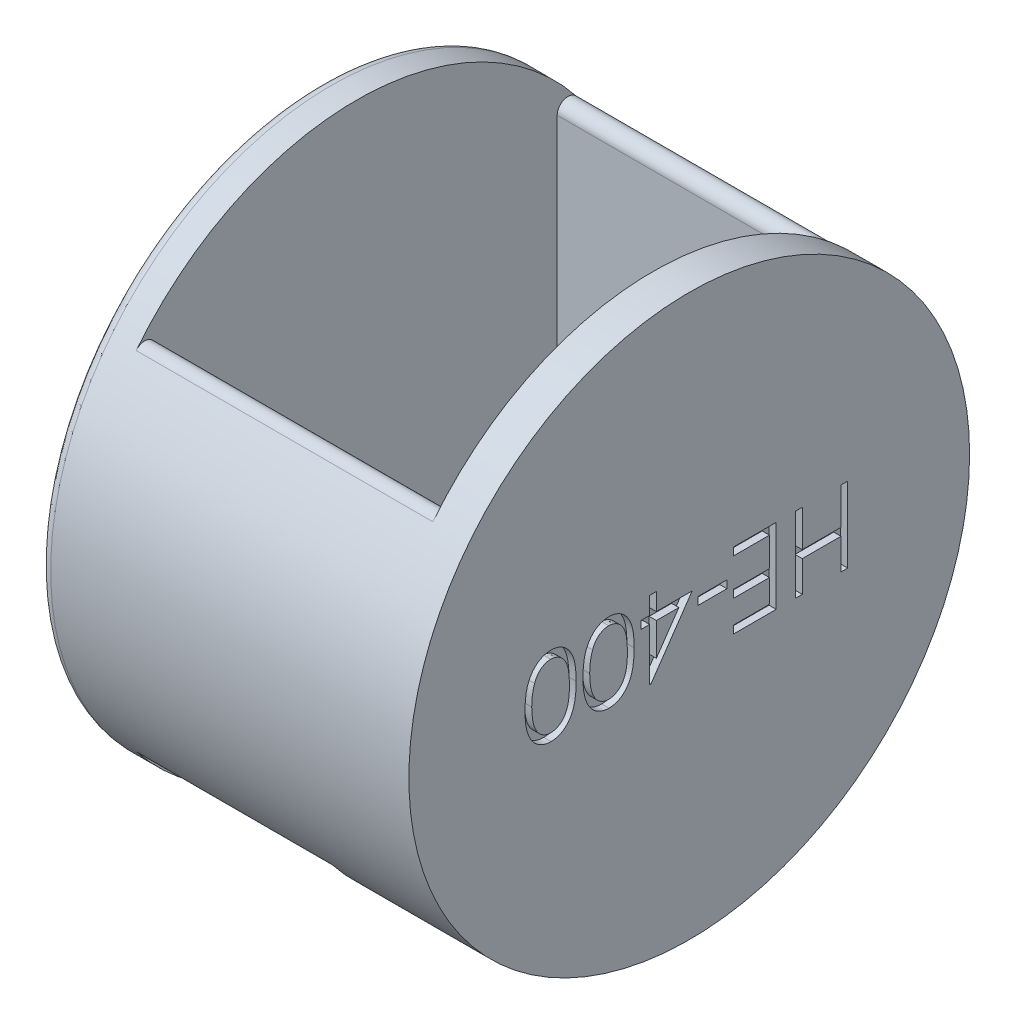
from build123d import *

# Parameters (mm, degrees)
SKETCH1_R                = 14.097
BOSS_EXTRUDE1_DEPTH      = 2.54
SKETCH1_4_R              = 19.685
SKETCH1_4_R_2            = 14.097
BOSS_EXTRUDE2_DEPTH      = 23.368
SKETCH2_R                = 19.685
BOSS_EXTRUDE3_DEPTH      = 2.54
CUT_EXTRUDE14_DEPTH      = 52.075635963
CUT_EXTRUDE14_DEPTH_BACK = 52.075635963
SKETCH5_W                = 13.716
SKETCH5_H                = 28.194
SKETCH5_7_W              = 7.112
SKETCH5_7_H              = 28.194
CUT_EXTRUDE15_DEPTH      = 19.685
SKETCH6_W                = 2.03525641
SKETCH6_H                = 0.542735043
CUT_EXTRUDE16_DEPTH      = 0.508
FILLET1_R                = 0.762


with BuildPart() as part:
    # Sketch1 → Boss-Extrude1 (new body)
    with BuildSketch(Plane(origin=(0, 0, 0), x_dir=(0, 0, -1), z_dir=(1, 0, 0))):
        Circle(SKETCH1_R)
    extrude(amount=BOSS_EXTRUDE1_DEPTH)

    # Sketch1_4 → Boss-Extrude2 (add)
    with BuildSketch(Plane(origin=(0, 0, 0), x_dir=(0, 0, -1), z_dir=(1, 0, 0))):
        Circle(SKETCH1_4_R)
        Circle(SKETCH1_4_R_2, mode=Mode.SUBTRACT)
    extrude(amount=BOSS_EXTRUDE2_DEPTH)

    # Sketch2 → Boss-Extrude3 (add)
    with BuildSketch(Plane(origin=(23.368, 0, 0), x_dir=(0, 0, -1), z_dir=(1, 0, 0))):
        Circle(SKETCH2_R)
    extrude(amount=BOSS_EXTRUDE3_DEPTH)

    # Sketch5 → Cut-Extrude14 (cut, two sides: drawn at the far end of the back side and taken through both)
    with BuildSketch(Plane(origin=(0, 19.685, 0), x_dir=(1, 0, 0), z_dir=(0, 1, 0)).offset(-CUT_EXTRUDE14_DEPTH_BACK)):
        with Locations((9.398, 0)):
            Rectangle(SKETCH5_W, SKETCH5_H)
    extrude(amount=CUT_EXTRUDE14_DEPTH + CUT_EXTRUDE14_DEPTH_BACK, mode=Mode.SUBTRACT)

    # Sketch5_7 → Cut-Extrude15 (cut)
    with BuildSketch(Plane(origin=(0, 19.685, 0), x_dir=(1, 0, 0), z_dir=(0, 1, 0))):
        with Locations((19.812, 0)):
            Rectangle(SKETCH5_7_W, SKETCH5_7_H)
    extrude(amount=-CUT_EXTRUDE15_DEPTH, mode=Mode.SUBTRACT)

    # Sketch6 → Cut-Extrude16 (cut)
    # profile 1 of 6: a face of its own
    with BuildSketch(Plane(origin=(25.908, 0, 0), x_dir=(0, 0, -1), z_dir=(1, 0, 0))):
        with BuildLine():
            add(Edge.make_bspline(
                [(-7.9375, 0.002120016), (-7.937995932, -0.082693891), (-7.938959288, -0.247446129), (-7.949676305, -0.487513385), (-7.9674795, -0.712727157), (-7.991877676, -0.923098217), (-8.021568415, -1.1186809), (-8.061203789, -1.298952445), (-8.106277723, -1.464747501), (-8.158518351, -1.616605725), (-8.217462038, -1.756576419), (-8.281626134, -1.887235952), (-8.353512856, -2.008428241), (-8.429168701, -2.121938907), (-8.511241484, -2.226625612), (-8.599445794, -2.322017877), (-8.693004723, -2.409593944), (-8.792360964, -2.48791374), (-8.896567528, -2.556158994), (-9.00254185, -2.618021773), (-9.113306534, -2.666956938), (-9.226129508, -2.708802141), (-9.341919763, -2.741949196), (-9.460727739, -2.765005575), (-9.58266005, -2.779430136), (-9.664953796, -2.780814869), (-9.706689036, -2.781517136)],
                knots=[0, 0, 0, 0, 1.64625301, 3.197870201, 4.6634513, 6.030635694, 7.308242971, 8.501545196, 9.611429483, 10.641742253, 11.616230371, 12.55791849, 13.464870342, 14.34944951, 15.20427819, 16.044004467, 16.869007726, 17.689551165, 18.496129964, 19.285613293, 20.0683943, 20.843080271, 21.620342827, 22.403213977, 23.190190624, 24, 24, 24, 24], degree=3))
            add(Edge.make_bspline(
                [(-9.706689036, -2.781517136), (-9.748794038, -2.780933163), (-9.832568173, -2.779771262), (-9.955977623, -2.763416809), (-10.077237491, -2.742307643), (-10.194508026, -2.708452016), (-10.310006587, -2.667939368), (-10.420860957, -2.614483573), (-10.530984882, -2.556346245), (-10.635375579, -2.485423594), (-10.737152051, -2.407042394), (-10.832556867, -2.318059694), (-10.92402883, -2.2209381), (-11.008113079, -2.113511516), (-11.088413348, -1.997427109), (-11.161881358, -1.87171176), (-11.23004511, -1.736644069), (-11.2941859, -1.592850191), (-11.350275328, -1.436489169), (-11.400143312, -1.268536268), (-11.441018564, -1.087470592), (-11.474821678, -0.894300793), (-11.501059329, -0.68806991), (-11.520154648, -0.469195791), (-11.530244865, -0.237541505), (-11.532144715, -0.079157565), (-11.533119658, 0.002120016)],
                knots=[0, 0, 0, 0, 0.810910589, 1.61342667, 2.396193133, 3.181089899, 3.963115317, 4.752255436, 5.550715454, 6.36105385, 7.181178335, 8.024612154, 8.872680183, 9.750181803, 10.651284446, 11.591556747, 12.554036451, 13.566402641, 14.62422919, 15.753422176, 16.94128843, 18.199818041, 19.531985927, 20.947085226, 22.433341622, 24, 24, 24, 24], degree=3))
            add(Edge.make_bspline(
                [(-11.533119658, 0.002120016), (-11.532122052, 0.083042058), (-11.530173906, 0.241068301), (-11.520384288, 0.471695291), (-11.500547447, 0.689375069), (-11.476369925, 0.894423013), (-11.441510668, 1.086571091), (-11.402701899, 1.266851209), (-11.353199136, 1.43356942), (-11.298440137, 1.588590152), (-11.235191822, 1.731774906), (-11.167541426, 1.866285081), (-11.092976705, 1.991286968), (-11.014217251, 2.108107177), (-10.92854112, 2.214612444), (-10.838307045, 2.312820461), (-10.741976654, 2.401957757), (-10.639676263, 2.481264427), (-10.534298886, 2.552721332), (-10.424153492, 2.612931661), (-10.311818484, 2.665422781), (-10.196125432, 2.707619502), (-10.077812077, 2.740976177), (-9.956452353, 2.763683561), (-9.832551669, 2.779689407), (-9.748788517, 2.780905727), (-9.706689036, 2.781517052)],
                knots=[0, 0, 0, 0, 1.561431216, 3.049195289, 4.452146966, 5.778046447, 7.031138842, 8.218704273, 9.334037798, 10.384210803, 11.388620812, 12.352076869, 13.287433199, 14.19507451, 15.06813243, 15.922055533, 16.766344942, 17.596869952, 18.417486629, 19.220035357, 20.016159057, 20.807716045, 21.59340902, 22.384936649, 23.188266813, 24, 24, 24, 24], degree=3))
            add(Edge.make_bspline(
                [(-9.706689036, 2.781517052), (-9.664955251, 2.780808561), (-9.582664372, 2.779411555), (-9.460711052, 2.765076893), (-9.342075341, 2.741701887), (-9.226520072, 2.70995875), (-9.113808787, 2.669615088), (-9.005045495, 2.618299506), (-8.898794221, 2.558781187), (-8.795538229, 2.491068822), (-8.697251465, 2.413468923), (-8.603348026, 2.327658184), (-8.51628577, 2.231425166), (-8.434778993, 2.126305823), (-8.358495409, 2.012509414), (-8.286913108, 1.890389332), (-8.222944414, 1.758456952), (-8.162664248, 1.617726417), (-8.109526822, 1.464752379), (-8.063128202, 1.298389167), (-8.024009944, 1.11750203), (-7.992851705, 0.922082309), (-7.967326159, 0.712432527), (-7.949693856, 0.488218596), (-7.938964646, 0.249920762), (-7.937997124, 0.086227578), (-7.9375, 0.002120016)],
                knots=[0, 0, 0, 0, 0.810976328, 1.599087026, 2.383086309, 3.159618043, 3.926613167, 4.707144544, 5.494386734, 6.292609454, 7.104690378, 7.92621526, 8.762510248, 9.62398222, 10.509836085, 11.424023232, 12.373226806, 13.358118208, 14.398657954, 15.5185989, 16.713620699, 17.994156382, 19.364120462, 20.818119981, 22.365111093, 24, 24, 24, 24], degree=3))
        make_face()
        with BuildLine():
            add(Edge.make_bspline(
                [(-8.412393162, -4.2e-08), (-8.412577715, 0.070679255), (-8.412935895, 0.207853894), (-8.422022303, 0.406839949), (-8.434669655, 0.592746077), (-8.450580757, 0.765499715), (-8.474409875, 0.924497116), (-8.501445528, 1.070399217), (-8.533872934, 1.202936193), (-8.572430256, 1.323265481), (-8.616348478, 1.433093612), (-8.664223235, 1.535338827), (-8.716081944, 1.631244786), (-8.773114398, 1.720465462), (-8.836137709, 1.802502535), (-8.903745174, 1.877745626), (-8.976329911, 1.945888366), (-9.076787042, 2.026759991), (-9.208764022, 2.111314187), (-9.375899671, 2.184038831), (-9.547714784, 2.230037038), (-9.664365492, 2.235870398), (-9.722589476, 2.238782009)],
                knots=[0, 0, 0, 0, 1.459193451, 2.832007961, 4.111736495, 5.306635028, 6.412683014, 7.430020708, 8.369596877, 9.227877302, 10.036669781, 10.810175692, 11.557788084, 12.286326232, 12.994037279, 13.69140682, 14.37267704, 15.047194847, 16.352618509, 17.594157723, 18.799169539, 20, 20, 20, 20], degree=3))
            add(Edge.make_bspline(
                [(-9.722589476, 2.238782009), (-9.781147793, 2.236228925), (-9.898056707, 2.231131813), (-10.069754872, 2.186646233), (-10.235061227, 2.114326806), (-10.365519249, 2.031703575), (-10.464493977, 1.952515004), (-10.535433901, 1.885076976), (-10.600537976, 1.809544273), (-10.662287759, 1.728054835), (-10.718922187, 1.639044922), (-10.770422444, 1.542944454), (-10.817417495, 1.439486028), (-10.844191887, 1.367262736), (-10.857880943, 1.33033683)],
                knots=[0, 0, 0, 0, 1.353621445, 2.702441307, 4.075953605, 5.516772412, 6.261413105, 7.007624062, 7.778524365, 8.566925914, 9.372323995, 10.217594641, 11.088702136, 12, 12, 12, 12], degree=3))
            add(Edge.make_bspline(
                [(-10.857880943, 1.33033683), (-10.873834211, 1.283120438), (-10.906226186, 1.187250914), (-10.947972559, 1.03853444), (-10.980849532, 0.882501689), (-11.010427478, 0.720085144), (-11.030616027, 0.550087025), (-11.046865697, 0.373033325), (-11.056437093, 0.188790551), (-11.057623561, 0.06361241), (-11.058226496, -4.2e-08)],
                knots=[0, 0, 0, 0, 0.884706709, 1.796334032, 2.740027952, 3.714592787, 4.726048262, 5.777819803, 6.87074269, 8, 8, 8, 8], degree=3))
            add(Edge.make_bspline(
                [(-11.058226496, -4.2e-08), (-11.057561524, -0.063611127), (-11.056260535, -0.1880634), (-11.047712924, -0.370137188), (-11.033977623, -0.543370241), (-11.015387194, -0.707919709), (-10.989866471, -0.863492719), (-10.959218606, -1.010311872), (-10.923287556, -1.148337659), (-10.88207338, -1.27792579), (-10.835626237, -1.398611346), (-10.784313786, -1.510654121), (-10.729564349, -1.614658415), (-10.670059375, -1.710289705), (-10.606640761, -1.798106005), (-10.537031365, -1.876085838), (-10.465652722, -1.948022706), (-10.364137186, -2.028669234), (-10.232316193, -2.111546858), (-10.067154872, -2.185741148), (-9.896220027, -2.229651331), (-9.780424595, -2.235740701), (-9.722589476, -2.238782094)],
                knots=[0, 0, 0, 0, 1.313528337, 2.569860077, 3.762944266, 4.901481389, 5.988248151, 7.017139294, 7.997571128, 8.932104357, 9.823695246, 10.66607014, 11.475539426, 12.248954257, 12.990316782, 13.708962568, 14.405488541, 15.08007697, 16.381737273, 17.610043218, 18.806313575, 20, 20, 20, 20], degree=3))
            add(Edge.make_bspline(
                [(-9.722589476, -2.238782094), (-9.664051396, -2.235737102), (-9.546868594, -2.229641571), (-9.374145575, -2.18589607), (-9.207995524, -2.112074551), (-9.076452321, -2.02856675), (-8.976365918, -1.948335902), (-8.905142646, -1.879860571), (-8.837926465, -1.80532116), (-8.77520507, -1.723656045), (-8.718520589, -1.634605498), (-8.666031584, -1.5393948), (-8.618538786, -1.437301467), (-8.57445479, -1.327534037), (-8.536306583, -1.207007026), (-8.502006897, -1.074496482), (-8.475532701, -0.927645516), (-8.452025942, -0.767901464), (-8.434257504, -0.594942434), (-8.422110448, -0.408596221), (-8.412908297, -0.208916514), (-8.412568313, -0.071033637), (-8.412393162, -4.2e-08)],
                knots=[0, 0, 0, 0, 1.207779899, 2.417760083, 3.652287919, 4.947299644, 5.621638849, 6.297435916, 6.984320042, 7.691843698, 8.42018894, 9.161205785, 9.934506883, 10.743085206, 11.601138371, 12.542248028, 13.566483018, 14.679455109, 15.87477181, 17.154161492, 18.533899613, 20, 20, 20, 20], degree=3))
        make_face(mode=Mode.SUBTRACT)
    # profile 2 of 6: a face of its own
    with BuildSketch(Plane(origin=(25.908, 0, 0), x_dir=(0, 0, -1), z_dir=(1, 0, 0))):
        with BuildLine():
            add(Edge.make_bspline(
                [(-3.866987179, 0.002120016), (-3.867483112, -0.082693891), (-3.868446467, -0.247446129), (-3.879163485, -0.487513385), (-3.89696668, -0.712727157), (-3.921364855, -0.923098217), (-3.951055595, -1.1186809), (-3.990690969, -1.298952445), (-4.035764902, -1.464747501), (-4.08800553, -1.616605725), (-4.146949218, -1.756576419), (-4.211113313, -1.887235952), (-4.283000035, -2.008428241), (-4.358655881, -2.121938907), (-4.440728663, -2.226625612), (-4.528932974, -2.322017877), (-4.622491902, -2.409593944), (-4.721848143, -2.48791374), (-4.826054708, -2.556158994), (-4.932029029, -2.618021773), (-5.042793713, -2.666956938), (-5.155616688, -2.708802141), (-5.271406943, -2.741949196), (-5.390214919, -2.765005575), (-5.512147229, -2.779430136), (-5.594440976, -2.780814869), (-5.636176215, -2.781517136)],
                knots=[0, 0, 0, 0, 1.64625301, 3.197870201, 4.6634513, 6.030635694, 7.308242971, 8.501545196, 9.611429483, 10.641742253, 11.616230371, 12.55791849, 13.464870342, 14.34944951, 15.20427819, 16.044004467, 16.869007726, 17.689551165, 18.496129964, 19.285613293, 20.0683943, 20.843080271, 21.620342827, 22.403213977, 23.190190624, 24, 24, 24, 24], degree=3))
            add(Edge.make_bspline(
                [(-5.636176215, -2.781517136), (-5.678281217, -2.780933163), (-5.762055352, -2.779771262), (-5.885464803, -2.763416809), (-6.006724671, -2.742307643), (-6.123995205, -2.708452016), (-6.239493766, -2.667939368), (-6.350348136, -2.614483573), (-6.460472061, -2.556346245), (-6.564862758, -2.485423594), (-6.66663923, -2.407042394), (-6.762044047, -2.318059694), (-6.85351601, -2.2209381), (-6.937600259, -2.113511516), (-7.017900528, -1.997427109), (-7.091368538, -1.87171176), (-7.159532289, -1.736644069), (-7.22367308, -1.592850191), (-7.279762507, -1.436489169), (-7.329630492, -1.268536268), (-7.370505743, -1.087470592), (-7.404308857, -0.894300793), (-7.430546509, -0.68806991), (-7.449641828, -0.469195791), (-7.459732044, -0.237541505), (-7.461631895, -0.079157565), (-7.462606838, 0.002120016)],
                knots=[0, 0, 0, 0, 0.810910589, 1.61342667, 2.396193133, 3.181089899, 3.963115317, 4.752255436, 5.550715454, 6.36105385, 7.181178335, 8.024612154, 8.872680183, 9.750181803, 10.651284446, 11.591556747, 12.554036451, 13.566402641, 14.62422919, 15.753422176, 16.94128843, 18.199818041, 19.531985927, 20.947085226, 22.433341622, 24, 24, 24, 24], degree=3))
            add(Edge.make_bspline(
                [(-7.462606838, 0.002120016), (-7.461609232, 0.083042058), (-7.459661086, 0.241068301), (-7.449871467, 0.471695291), (-7.430034626, 0.689375069), (-7.405857104, 0.894423013), (-7.370997848, 1.086571091), (-7.332189079, 1.266851209), (-7.282686316, 1.43356942), (-7.227927317, 1.588590152), (-7.164679002, 1.731774906), (-7.097028605, 1.866285081), (-7.022463885, 1.991286968), (-6.943704431, 2.108107177), (-6.858028299, 2.214612444), (-6.767794224, 2.312820461), (-6.671463833, 2.401957757), (-6.569163442, 2.481264427), (-6.463786065, 2.552721332), (-6.353640672, 2.612931661), (-6.241305663, 2.665422781), (-6.125612612, 2.707619502), (-6.007299257, 2.740976177), (-5.885939533, 2.763683561), (-5.762038848, 2.779689407), (-5.678275697, 2.780905727), (-5.636176215, 2.781517052)],
                knots=[0, 0, 0, 0, 1.561431216, 3.049195289, 4.452146966, 5.778046447, 7.031138842, 8.218704273, 9.334037798, 10.384210803, 11.388620812, 12.352076869, 13.287433199, 14.19507451, 15.06813243, 15.922055533, 16.766344942, 17.596869952, 18.417486629, 19.220035357, 20.016159057, 20.807716045, 21.59340902, 22.384936649, 23.188266813, 24, 24, 24, 24], degree=3))
            add(Edge.make_bspline(
                [(-5.636176215, 2.781517052), (-5.59444243, 2.780808561), (-5.512151552, 2.779411555), (-5.390198231, 2.765076893), (-5.271562521, 2.741701887), (-5.156007252, 2.70995875), (-5.043295966, 2.669615088), (-4.934532675, 2.618299506), (-4.828281401, 2.558781187), (-4.725025408, 2.491068822), (-4.626738644, 2.413468923), (-4.532835206, 2.327658184), (-4.44577295, 2.231425166), (-4.364266172, 2.126305823), (-4.287982589, 2.012509414), (-4.216400287, 1.890389332), (-4.152431593, 1.758456952), (-4.092151428, 1.617726417), (-4.039014001, 1.464752379), (-3.992615381, 1.298389167), (-3.953497123, 1.11750203), (-3.922338885, 0.922082309), (-3.896813339, 0.712432527), (-3.879181036, 0.488218596), (-3.868451826, 0.249920762), (-3.867484304, 0.086227578), (-3.866987179, 0.002120016)],
                knots=[0, 0, 0, 0, 0.810976328, 1.599087026, 2.383086309, 3.159618043, 3.926613167, 4.707144544, 5.494386734, 6.292609454, 7.104690378, 7.92621526, 8.762510248, 9.62398222, 10.509836085, 11.424023232, 12.373226806, 13.358118208, 14.398657954, 15.5185989, 16.713620699, 17.994156382, 19.364120462, 20.818119981, 22.365111093, 24, 24, 24, 24], degree=3))
        make_face()
        with BuildLine():
            add(Edge.make_bspline(
                [(-4.341880342, -4.2e-08), (-4.342064894, 0.070679255), (-4.342423075, 0.207853894), (-4.351509483, 0.406839949), (-4.364156835, 0.592746077), (-4.380067937, 0.765499715), (-4.403897054, 0.924497116), (-4.430932708, 1.070399217), (-4.463360114, 1.202936193), (-4.501917435, 1.323265481), (-4.545835658, 1.433093612), (-4.593710415, 1.535338827), (-4.645569124, 1.631244786), (-4.702601578, 1.720465462), (-4.765624889, 1.802502535), (-4.833232354, 1.877745626), (-4.90581709, 1.945888366), (-5.006274221, 2.026759991), (-5.138251201, 2.111314187), (-5.30538685, 2.184038831), (-5.477201963, 2.230037038), (-5.593852671, 2.235870398), (-5.652076656, 2.238782009)],
                knots=[0, 0, 0, 0, 1.459193451, 2.832007961, 4.111736495, 5.306635028, 6.412683014, 7.430020708, 8.369596877, 9.227877302, 10.036669781, 10.810175692, 11.557788084, 12.286326232, 12.994037279, 13.69140682, 14.37267704, 15.047194847, 16.352618509, 17.594157723, 18.799169539, 20, 20, 20, 20], degree=3))
            add(Edge.make_bspline(
                [(-5.652076656, 2.238782009), (-5.710634972, 2.236228925), (-5.827543887, 2.231131813), (-5.999242052, 2.186646233), (-6.164548406, 2.114326806), (-6.295006429, 2.031703575), (-6.393981156, 1.952515004), (-6.46492108, 1.885076976), (-6.530025155, 1.809544273), (-6.591774939, 1.728054835), (-6.648409367, 1.639044922), (-6.699909623, 1.542944454), (-6.746904674, 1.439486028), (-6.773679066, 1.367262736), (-6.787368122, 1.33033683)],
                knots=[0, 0, 0, 0, 1.353621445, 2.702441307, 4.075953605, 5.516772412, 6.261413105, 7.007624062, 7.778524365, 8.566925914, 9.372323995, 10.217594641, 11.088702136, 12, 12, 12, 12], degree=3))
            add(Edge.make_bspline(
                [(-6.787368122, 1.33033683), (-6.80332139, 1.283120438), (-6.835713366, 1.187250914), (-6.877459739, 1.03853444), (-6.910336712, 0.882501689), (-6.939914657, 0.720085144), (-6.960103206, 0.550087025), (-6.976352876, 0.373033325), (-6.985924272, 0.188790551), (-6.987110741, 0.06361241), (-6.987713675, -4.2e-08)],
                knots=[0, 0, 0, 0, 0.884706709, 1.796334032, 2.740027952, 3.714592787, 4.726048262, 5.777819803, 6.87074269, 8, 8, 8, 8], degree=3))
            add(Edge.make_bspline(
                [(-6.987713675, -4.2e-08), (-6.987048703, -0.063611127), (-6.985747715, -0.1880634), (-6.977200104, -0.370137188), (-6.963464803, -0.543370241), (-6.944874374, -0.707919709), (-6.91935365, -0.863492719), (-6.888705785, -1.010311872), (-6.852774736, -1.148337659), (-6.811560559, -1.27792579), (-6.765113416, -1.398611346), (-6.713800965, -1.510654121), (-6.659051528, -1.614658415), (-6.599546555, -1.710289705), (-6.53612794, -1.798106005), (-6.466518544, -1.876085838), (-6.395139901, -1.948022706), (-6.293624366, -2.028669234), (-6.161803373, -2.111546858), (-5.996642052, -2.185741148), (-5.825707207, -2.229651331), (-5.709911775, -2.235740701), (-5.652076656, -2.238782094)],
                knots=[0, 0, 0, 0, 1.313528337, 2.569860077, 3.762944266, 4.901481389, 5.988248151, 7.017139294, 7.997571128, 8.932104357, 9.823695246, 10.66607014, 11.475539426, 12.248954257, 12.990316782, 13.708962568, 14.405488541, 15.08007697, 16.381737273, 17.610043218, 18.806313575, 20, 20, 20, 20], degree=3))
            add(Edge.make_bspline(
                [(-5.652076656, -2.238782094), (-5.593538576, -2.235737102), (-5.476355773, -2.229641571), (-5.303632755, -2.18589607), (-5.137482704, -2.112074551), (-5.0059395, -2.02856675), (-4.905853098, -1.948335902), (-4.834629826, -1.879860571), (-4.767413645, -1.80532116), (-4.70469225, -1.723656045), (-4.648007768, -1.634605498), (-4.595518763, -1.5393948), (-4.548025965, -1.437301467), (-4.503941969, -1.327534037), (-4.465793762, -1.207007026), (-4.431494077, -1.074496482), (-4.405019881, -0.927645516), (-4.381513121, -0.767901464), (-4.363744683, -0.594942434), (-4.351597628, -0.408596221), (-4.342395477, -0.208916514), (-4.342055493, -0.071033637), (-4.341880342, -4.2e-08)],
                knots=[0, 0, 0, 0, 1.207779899, 2.417760083, 3.652287919, 4.947299644, 5.621638849, 6.297435916, 6.984320042, 7.691843698, 8.42018894, 9.161205785, 9.934506883, 10.743085206, 11.601138371, 12.542248028, 13.566483018, 14.679455109, 15.87477181, 17.154161492, 18.533899613, 20, 20, 20, 20], degree=3))
        make_face(mode=Mode.SUBTRACT)
    # profile 3 of 6: a face of its own
    with BuildSketch(Plane(origin=(25.908, 0, 0), x_dir=(0, 0, -1), z_dir=(1, 0, 0))):
        Polygon((-2.68505442, -2.781517136), (-2.781517094, -2.781517136), (-2.781517094, 0.881944402), (-3.392094017, 0.881944402), (-3.392094017, 1.424679445), (-2.781517094, 1.424679445), (-2.781517094, 2.645833291), (-2.306623932, 2.645833291), (-2.306623932, 1.424679445), (0.203525641, 1.424679445), align=None)
        Polygon((-2.306623932, 0.881944402), (-2.306623932, -1.416199294), (-0.729300214, 0.881944402), align=None, mode=Mode.SUBTRACT)
    # profile 4 of 6: a face of its own
    with BuildSketch(Plane(origin=(25.908, 0, 0), x_dir=(0, 0, -1), z_dir=(1, 0, 0))):
        with Locations((1.628205128, 0.610576881)):
            Rectangle(SKETCH6_W, SKETCH6_H)
    # profile 5 of 6: a face of its own
    with BuildSketch(Plane(origin=(25.908, 0, 0), x_dir=(0, 0, -1), z_dir=(1, 0, 0))):
        Polygon((6.105769231, -2.645833376), (3.120726496, -2.645833376), (3.120726496, -2.103098333), (5.630876068, -2.103098333), (5.630876068, -0.474893205), (3.120726496, -0.474893205), (3.120726496, 0.067841838), (5.630876068, 0.067841838), (5.630876068, 2.103098248), (3.120726496, 2.103098248), (3.120726496, 2.645833291), (6.105769231, 2.645833291), align=None)
    # profile 6 of 6: a face of its own
    with BuildSketch(Plane(origin=(25.908, 0, 0), x_dir=(0, 0, -1), z_dir=(1, 0, 0))):
        Polygon((11.126068376, -2.645833376), (10.651175214, -2.645833376), (10.651175214, -0.474893205), (7.9375, -0.474893205), (7.9375, -2.645833376), (7.462606838, -2.645833376), (7.462606838, 2.645833291), (7.9375, 2.645833291), (7.9375, 0.067841838), (10.651175214, 0.067841838), (10.651175214, 2.645833291), (11.126068376, 2.645833291), align=None)
    extrude(amount=-CUT_EXTRUDE16_DEPTH, mode=Mode.SUBTRACT)

    # Fillet1
    fillet1_edges = [part.edges().sort_by_distance(p)[0] for p in [
        (12.954, 13.73949839, -14.097),
        (12.954, 13.73949839, 14.097),
        (9.398, -13.73949839, 14.097),
        (9.398, -13.73949839, -14.097),
        (0, 0, 19.685),
    ]]
    fillet(fillet1_edges, radius=FILLET1_R)


solid = part.part
